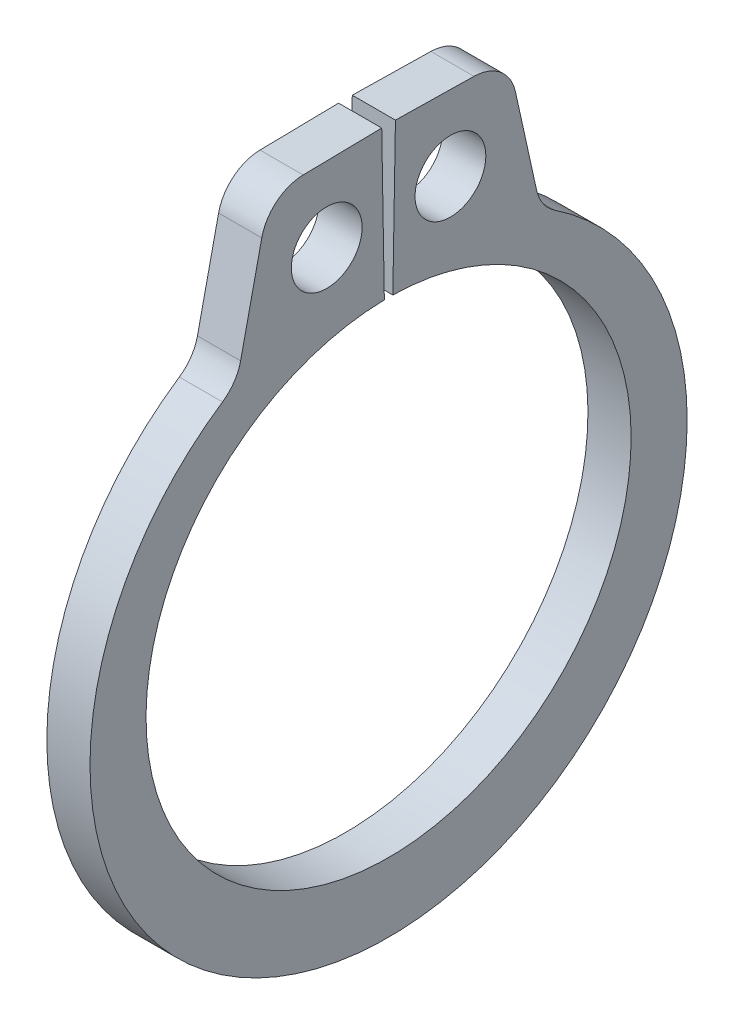
from build123d import *

# Parameters (mm, degrees)
SKETCH1_R      = 0.5207
EXTRUDE1_DEPTH = 0.3175
FILLET1_R      = 0.635


with BuildPart() as part:
    # Sketch1 → Extrude1 (new body, symmetric)
    with BuildSketch(Plane(origin=(0, 0, 0), x_dir=(0, 0, -1), z_dir=(1, 0, 0))):
        with BuildLine():
            Line((-0.062282403, 3.56815647), (-0.100848731, 5.777619906))
            Line((-0.100848731, 5.777619906), (-1.757946308, 5.748695161))
            Line((-1.757946308, 5.748695161), (-2.234134645, 3.590811774))
            ThreePointArc((-2.234134645, 3.590811774), (0, -4.5847), (2.234134645, 3.590811774))
            Line((2.234134645, 3.590811774), (1.757946308, 5.748695161))
            Line((1.757946308, 5.748695161), (0.100848731, 5.777619906))
            Line((0.100848731, 5.777619906), (0.062282403, 3.56815647))
            ThreePointArc((0.062282403, 3.56815647), (0, -3.5687), (-0.062282403, 3.56815647))
        make_face()
        with Locations((-0.910114356, 4.658425815)):
            Circle(SKETCH1_R, mode=Mode.SUBTRACT)
        with Locations((0.910114356, 4.658425815)):
            Circle(SKETCH1_R, mode=Mode.SUBTRACT)
    extrude(amount=EXTRUDE1_DEPTH, both=True)

    # Fillet1
    fillet1_edges = [part.edges().sort_by_distance(p)[0] for p in [
        (0, 5.748695161, -1.757946308),
        (0, 3.590811774, -2.234134645),
        (0, 3.590811774, 2.234134645),
        (0, 5.748695161, 1.757946308),
    ]]
    fillet(fillet1_edges, radius=FILLET1_R)


solid = part.part
